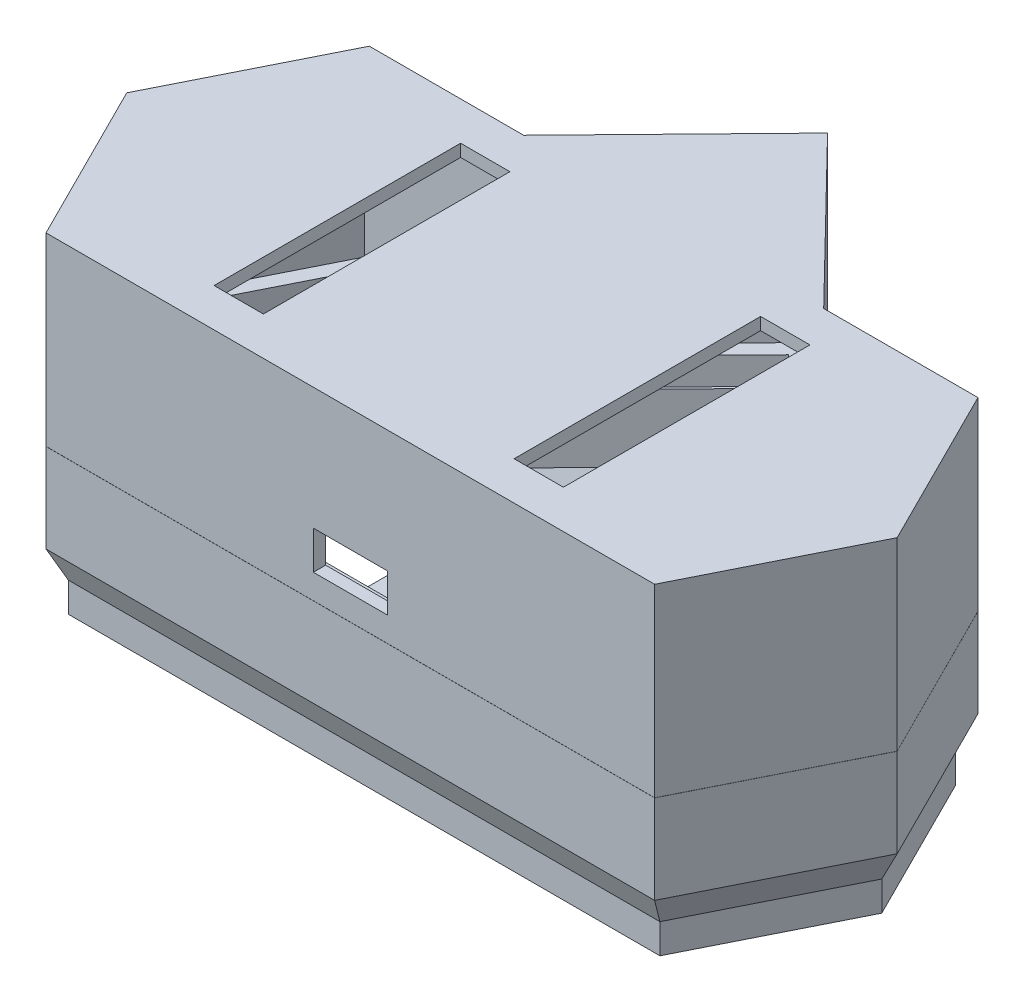
from build123d import *

# Parameters (mm, degrees)
BOSS_EXTRU_4_DEPTH       = 2
BOSS_EXTRU_5_DEPTH       = 2
BOSS_EXTRU_5_DRAFT       = -25
BOSS_EXTRU_6_DEPTH       = 5
COQUE2_T                 = -2
BOSS_EXTRU_7_DEPTH       = 1
ENL_V_MAT_EXTRU_9_DEPTH  = 31
ENL_V_MAT_EXTRU_10_DEPTH = 31
ENL_V_MAT_EXTRU_12_DEPTH = 31
ENL_V_MAT_EXTRU_13_DEPTH = 31
ENL_V_MAT_EXTRU_14_DEPTH = 31
ENL_V_MAT_EXTRU_15_DEPTH = 31
ECHELLE1_SCALE           = 1.2
BOSS_EXTRU_10_DEPTH      = 1.21
BOSS_EXTRU_12_DEPTH      = 15
COQUE3_T                 = -1
ESQUISSE16_W             = 4
ESQUISSE16_H             = 20
ENL_V_MAT_EXTRU_16_DEPTH = 5
ESQUISSE17_W             = 6
ESQUISSE17_H             = 3.1
ENL_V_MAT_EXTRU_17_DEPTH = 5


with BuildPart() as part:
    # Esquisse1 → Boss.-Extru.4 (new body)
    with BuildSketch(Plane(origin=(0, 0, 0), x_dir=(1, 0, 0), z_dir=(0, 1, 0))):
        Polygon((-19.997928578, 9.999644375), (-9.748317972, 9.999644375), (0, 19.999288751), (9.748317972, 9.999644375), (19.997928578, 9.999644375), (25.000322964, 0), (19.997928578, -9.995978997), (-19.997928578, -9.995978997), (-25.000322964, 0), align=None)
    extrude(amount=BOSS_EXTRU_4_DEPTH)


with BuildPart() as boss_extru_5_tool:
    # Esquisse5 → Boss.-Extru.5 (with draft: the straight prism first)
    with BuildSketch(Plane(origin=(0, 2, 0), x_dir=(1, 0, 0), z_dir=(0, 1, 0))):
        Polygon((-25.000322964, 0), (-19.997928578, -9.995978997), (19.997928578, -9.995978997), (25.000322964, 0), (19.997928578, 9.999644375), (9.748317972, 9.999644375), (0, 19.999288751), (-9.748317972, 9.999644375), (-19.997928578, 9.999644375), align=None)
    extrude(amount=BOSS_EXTRU_5_DEPTH)
    # Boss.-Extru.5: the draft: its side faces are tilted about the plane it starts from
    boss_extru_5_sides = [boss_extru_5_tool.faces().sort_by_distance(p)[0] for p in [
        (-22.499125771, 3, 4.997989499),
        (0, 3, 9.995978997),
        (22.499125771, 3, 4.997989499),
        (22.499125771, 3, -4.999822188),
        (14.873123275, 3, -9.999644375),
        (4.874158986, 3, -14.999466563),
        (-4.874158986, 3, -14.999466563),
        (-14.873123275, 3, -9.999644375),
        (-22.499125771, 3, -4.999822188),
    ]]
    draft(boss_extru_5_sides, Plane(origin=(0, 2, 0), x_dir=(1, 0, 0), z_dir=(0, 1, 0)), BOSS_EXTRU_5_DRAFT)


with BuildPart() as part_1:
    add(part.part)

    # Boss.-Extru.5: add boss_extru_5_tool
    add(boss_extru_5_tool.part)

    # Esquisse6 → Boss.-Extru.6 (add)
    with BuildSketch(Plane(origin=(0, 4, 0), x_dir=(1, 0, 0), z_dir=(0, 1, 0))):
        Polygon((-20.574183953, 10.932259692), (-26.04316416, -7.6497e-05), (-20.574089427, -10.928594314), (20.574089427, -10.928594314), (26.04316416, -7.6497e-05), (20.574183953, 10.932259692), (10.141590743, 10.932259692), (0, 21.335316006), (-10.141590743, 10.932259692), align=None)
    extrude(amount=BOSS_EXTRU_6_DEPTH)

    # Coque2
    coque2_openings = [part_1.faces().sort_by_distance(p)[0] for p in [
        (0, 9, -1.352523229),
    ]]
    offset(amount=COQUE2_T, openings=coque2_openings, kind=Kind.INTERSECTION)

    # Esquisse7 → Boss.-Extru.7 (add)
    with BuildSketch(Plane(origin=(0, 9, 0), x_dir=(1, 0, 0), z_dir=(0, 1, 0))):
        Polygon((-10.141590743, 10.932259692), (-20.574183953, 10.932259692), (-26.04316416, -7.6497e-05), (-20.574089427, -10.928594314), (20.574089427, -10.928594314), (26.04316416, -7.6497e-05), (20.574183953, 10.932259692), (10.141590743, 10.932259692), (0, 21.335316006), align=None)
        Polygon((-9.719902654, 9.932259692), (-19.956292134, 9.932259692), (-24.924974079, 5.527e-06), (-19.956298963, -9.928594314), (19.956298963, -9.928594314), (24.924974079, 5.527e-06), (19.956292134, 9.932259692), (9.719902654, 9.932259692), (0, 19.902756159), align=None, mode=Mode.SUBTRACT)
    extrude(amount=BOSS_EXTRU_7_DEPTH)

    # Esquisse8 → Enl_v. mat.-Extru.9 (cut)
    with BuildSketch(Plane.XZ):
        Polygon((-18.144253119, -6.999644375), (-9.483253704, -6.999644375), (-9.483253704, 6.995978997), (-18.144557186, 6.995978997), (-21.645752718, -0.000246072), align=None)
    extrude(amount=-ENL_V_MAT_EXTRU_9_DEPTH, mode=Mode.SUBTRACT)

    # Esquisse8_8 → Enl_v. mat.-Extru.10 (cut)
    with BuildSketch(Plane.XZ):
        Polygon((2.5, 4.25), (-2.5, 4.25), (-2.5, -0.000246072), (-2.5, -4.25), (0, -4.25), (2.5, -4.25), (2.5, -0.000246072), align=None)
    extrude(amount=-ENL_V_MAT_EXTRU_10_DEPTH, mode=Mode.SUBTRACT)

    # Esquisse8_11 → Enl_v. mat.-Extru.12 (cut)
    with BuildSketch(Plane.XZ):
        Polygon((18.144557186, 6.995978997), (9.483253704, 6.995978997), (9.483253704, -6.999644375), (18.144253119, -6.999644375), (21.645752718, -0.000246072), align=None)
    extrude(amount=-ENL_V_MAT_EXTRU_12_DEPTH, mode=Mode.SUBTRACT)

    # Esquisse8_12 → Enl_v. mat.-Extru.13 (cut)
    with BuildSketch(Plane.XZ):
        Polygon((-2.5, -6.999644375), (-8.483253704, -6.999644375), (-5.849198795, -9.701609209), (-2.5, -9.701609209), align=None)
    extrude(amount=-ENL_V_MAT_EXTRU_13_DEPTH, mode=Mode.SUBTRACT)

    # Esquisse8_13 → Enl_v. mat.-Extru.14 (cut)
    with BuildSketch(Plane.XZ):
        Polygon((2.5, -9.701609209), (5.849198795, -9.701609209), (8.483253704, -6.999644375), (2.5, -6.999644375), align=None)
    extrude(amount=-ENL_V_MAT_EXTRU_14_DEPTH, mode=Mode.SUBTRACT)

    # Esquisse8_14 → Enl_v. mat.-Extru.15 (cut)
    with BuildSketch(Plane.XZ):
        Polygon((4.874332329, -10.701609209), (-4.874332329, -10.701609209), (0, -15.701609209), align=None)
    extrude(amount=-ENL_V_MAT_EXTRU_15_DEPTH, mode=Mode.SUBTRACT)


with BuildPart() as part_2:
    # Echelle1: scaled about (0, 3.948557894, -1.526100481)
    add(part_1.part.scale(ECHELLE1_SCALE).moved(Location((0, -0.789711579, 0.305220096))))


with BuildPart() as body_2:
    # Esquisse11 → Boss.-Extru.10 (new body)
    with BuildSketch(Plane(origin=(0, 10.010288421, 0), x_dir=(1, 0, 0), z_dir=(0, 1, 0))):
        Polygon((0, 23.578087294), (-11.663883184, 11.613491534), (-23.94755056, 11.613491534), (-29.909968894, -0.305213464), (-23.947558756, -12.219533273), (23.947558756, -12.219533273), (29.909968894, -0.305213464), (23.94755056, 11.613491534), (11.663883184, 11.613491534), align=None)
    extrude(amount=BOSS_EXTRU_10_DEPTH)

    # Esquisse12 → Boss.-Extru.12 (add)
    with BuildSketch(Plane(origin=(0, 11.220288421, 0), x_dir=(1, 0, 0), z_dir=(0, 1, 0))):
        Polygon((12.169908892, 12.813491534), (0, 25.297159111), (-12.169908892, 12.813491534), (-24.689020744, 12.813491534), (-31.251796992, -0.305311893), (-24.688907313, -13.419533273), (24.688907313, -13.419533273), (31.251796992, -0.305311893), (24.689020744, 12.813491534), align=None)
    extrude(amount=BOSS_EXTRU_12_DEPTH)

    # Coque3
    coque3_openings = [body_2.faces().sort_by_distance(p)[0] for p in [
        (0, 10.010288421, -1.256526119),
    ]]
    offset(amount=COQUE3_T, openings=coque3_openings, kind=Kind.INTERSECTION)

    # Esquisse16 → Enl_v. mat.-Extru.16 (cut)
    with BuildSketch(Plane(origin=(0, 26.220288421, 0), x_dir=(1, 0, 0), z_dir=(0, 1, 0))):
        with Locations((-12.169908892, -0.303020869)):
            Rectangle(ESQUISSE16_W, ESQUISSE16_H)
        with Locations((12.169908892, -0.303020869)):
            Rectangle(ESQUISSE16_W, ESQUISSE16_H)
    extrude(amount=-ENL_V_MAT_EXTRU_16_DEPTH, mode=Mode.SUBTRACT)

    # Esquisse17 → Enl_v. mat.-Extru.17 (cut)
    with BuildSketch(Plane.XY.offset(13.419533273)):
        with Locations((0, 14.770288421)):
            Rectangle(ESQUISSE17_W, ESQUISSE17_H)
    extrude(amount=-ENL_V_MAT_EXTRU_17_DEPTH, mode=Mode.SUBTRACT)


solid = Compound([part_2.part, body_2.part])
